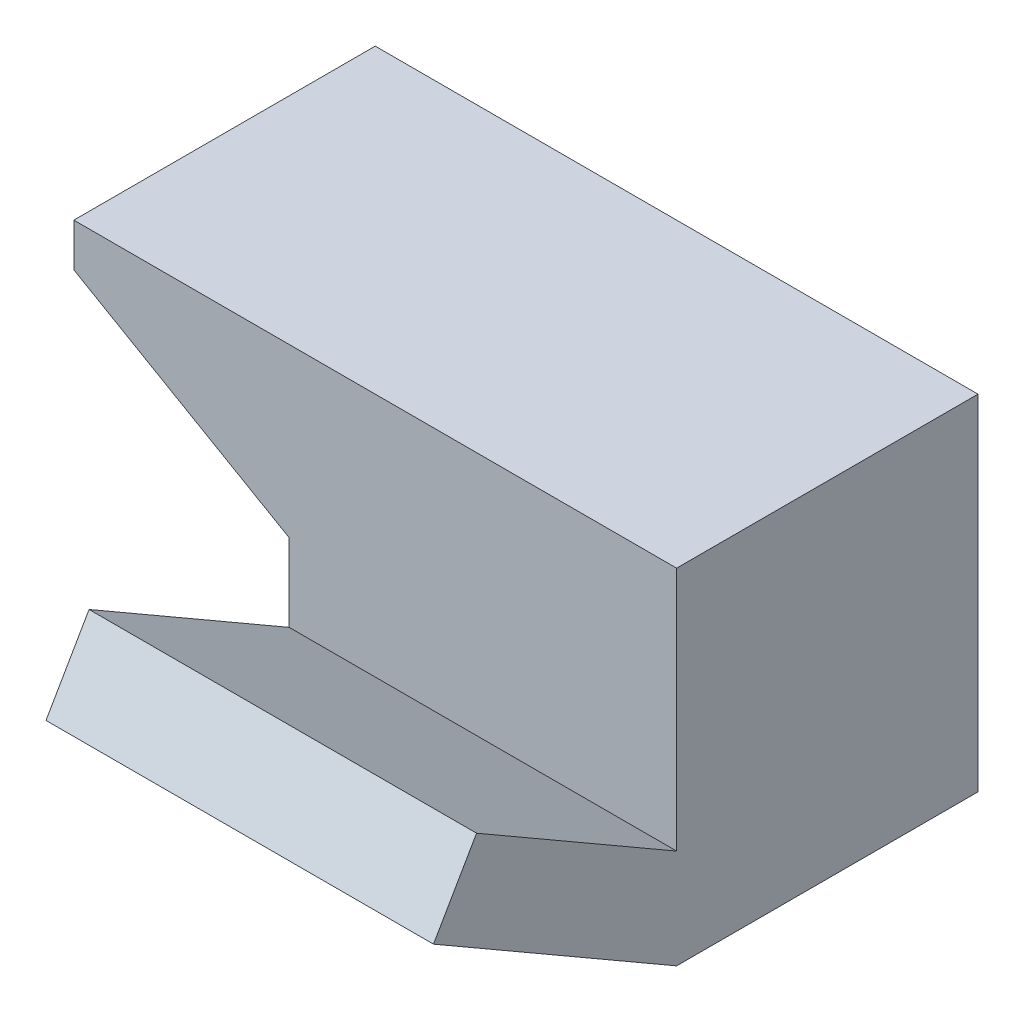
from build123d import *

# Parameters (mm, degrees)
BOSS_EXTRUDE1_DEPTH   = 44.45
SKETCH3_R             = 9.525
CUT_EXTRUDE1_DEPTH    = 6.35
BOSS_EXTRUDE2_DEPTH   = 57.15
SKETCH5_R             = 9.525
CUT_EXTRUDE2_DEPTH    = 6.35
SKETCH6_R             = 4.7625
CUT_EXTRUDE3_DEPTH    = 12.7
BODY_MOVE_COPY1_ANGLE = 180


with BuildPart() as part:
    # Sketch1 → Boss-Extrude1 (new body)
    with BuildSketch(Plane(origin=(0, 0, 0), x_dir=(1, 0, 0), z_dir=(0, 1, 0))):
        Polygon((57.15, 0), (88.9, 0), (88.9, 6.35), (57.15, 24.680871047), (57.15, 50.8), (0, 50.8), (0, 0), align=None)
    extrude(amount=BOSS_EXTRUDE1_DEPTH)

    # Sketch3 → Cut-Extrude1 (cut)
    with BuildSketch(Plane(origin=(24.974630657, 0, -43.257329198), x_dir=(-0.866025404, 0, -0.5), z_dir=(0.5, 0, -0.866025404))):
        with Locations((-54.764658396, 22.352)):
            Circle(SKETCH3_R)
    extrude(amount=-CUT_EXTRUDE1_DEPTH, mode=Mode.SUBTRACT)

    # Sketch4 → Boss-Extrude2 (add)
    with BuildSketch(Plane.ZY):
        Polygon((-50.8, 44.45), (-30.099, 80.305183767), (-19.100477372, 73.955183767), (-36.135303163, 44.45), (0, 44.45), (0, 0), (-50.8, 0), align=None)
    extrude(amount=-BOSS_EXTRUDE2_DEPTH)

    # Sketch5 → Cut-Extrude2 (cut)
    with BuildSketch(Plane(origin=(0, 33.109545256, -57.347414599), x_dir=(-1, 0, 0), z_dir=(0, 0.5, -0.866025404))):
        with Locations((-28.702, 35.446829198)):
            Circle(SKETCH5_R)
    extrude(amount=-CUT_EXTRUDE2_DEPTH, mode=Mode.SUBTRACT)

    # Sketch6 → Cut-Extrude3 (cut)
    with BuildSketch(Plane(origin=(0, 0, -50.8), x_dir=(-1, 0, 0), z_dir=(0, 0, -1))):
        with Locations((-41.148, 31.75)):
            Circle(SKETCH6_R)
        with Locations((-16.002, 31.75)):
            Circle(SKETCH6_R)
        with Locations((-16.002, 12.7)):
            Circle(SKETCH6_R)
        with Locations((-41.148, 12.7)):
            Circle(SKETCH6_R)
    extrude(amount=-CUT_EXTRUDE3_DEPTH, mode=Mode.SUBTRACT)


with BuildPart() as part_1:
    # Body-Move/Copy1: moved
    add(part.part.moved(Location((0, 0, 0))).rotate(Axis((44.45, 32.776295942, -32.776295942), (0, 0.707106781, 0.707106781)), BODY_MOVE_COPY1_ANGLE))


solid = part_1.part
